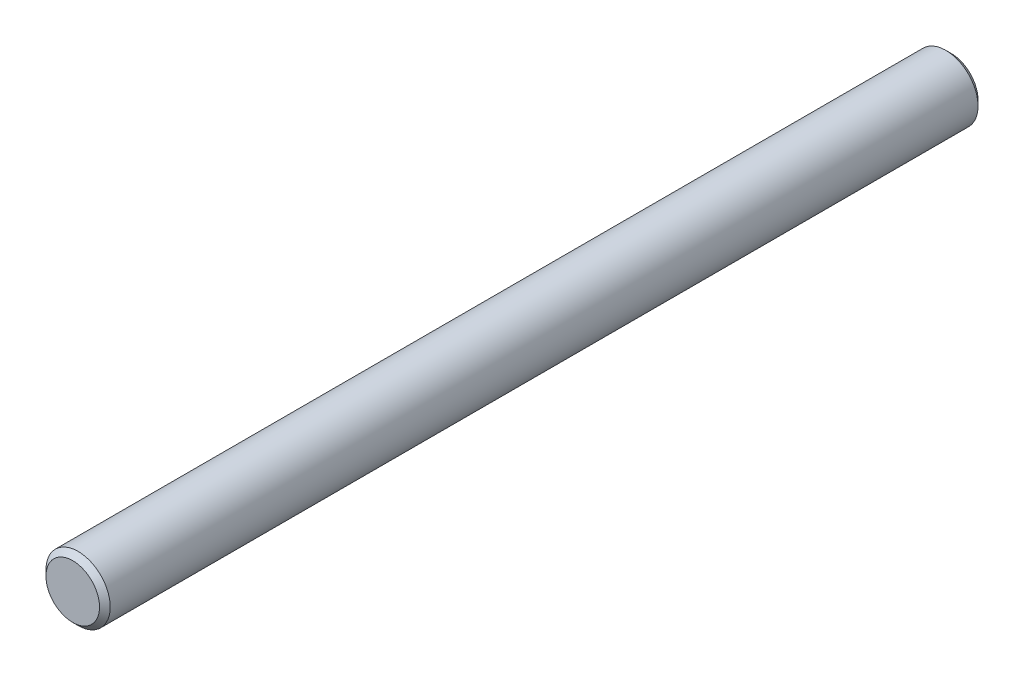
from build123d import *

# Parameters (mm, degrees)
SKETCH1_R              = 3
SHAFT_DEPTH            = 41
F_0_5X45_CHAMFERS_SIZE = 0.5


with BuildPart() as part:
    # Sketch1 → Shaft (new body, symmetric)
    with BuildSketch(Plane.XY):
        Circle(SKETCH1_R)
    extrude(amount=SHAFT_DEPTH, both=True)

    # 0.5x45 Chamfers
    f_0_5x45_chamfers_edges = [part.edges().sort_by_distance(p)[0] for p in [
        (-3, 0, -41),
        (-3, 0, 41),
    ]]
    chamfer(f_0_5x45_chamfers_edges, length=F_0_5X45_CHAMFERS_SIZE)


solid = part.part
